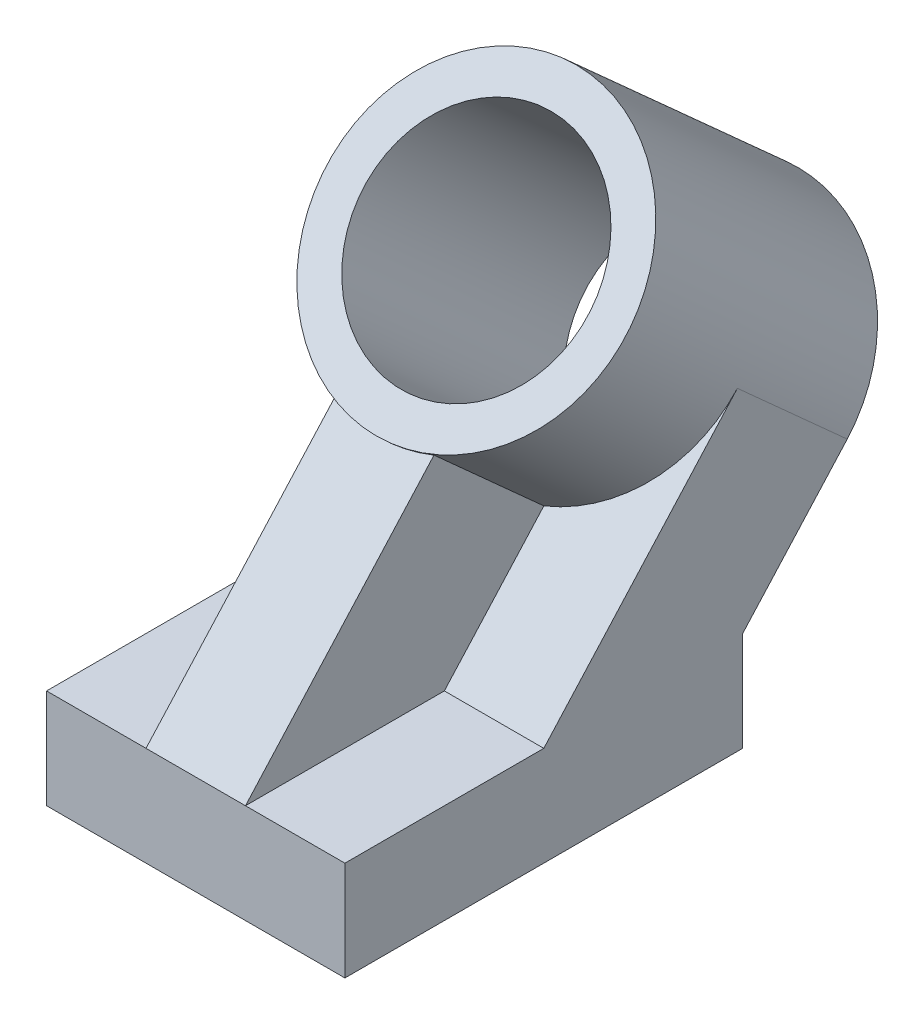
from build123d import *

# Parameters (mm, degrees)
BOSS_EXTRUDE1_DEPTH = 38.1
BOSS_EXTRUDE2_REACH = 114.341
SKETCH3_W           = 25.4
SKETCH3_H           = 88.161149917
SKETCH4_R           = 38.1
BOSS_EXTRUDE3_DEPTH = 76.2
SKETCH5_R           = 28.575
CUT_EXTRUDE1_DEPTH  = 76.2


with BuildPart() as part:
    # Sketch1 → Boss-Extrude1 (new body, symmetric)
    with BuildSketch(Plane(origin=(0, 0, 0), x_dir=(0, 0, -1), z_dir=(1, 0, 0))):
        Polygon((0, 0), (0, 25.4), (50.8, 25.4), (100.244555556, 80.313742191), (128.299578523, 55.052886048), (101.6, 25.4), (101.6, 0), align=None)
    extrude(amount=BOSS_EXTRUDE1_DEPTH, both=True)

    # Sketch3 → Boss-Extrude2 (add, up to next)
    with BuildSketch(Plane(origin=(0, 11.372488517, 12.630428071), x_dir=(1, 0, 0), z_dir=(0, 0.669130606, 0.743144825)), mode=Mode.PRIVATE) as boss_extrude2_sk1:
        with Locations((0, 62.956453526)):
            Rectangle(SKETCH3_W, SKETCH3_H)
    boss_extrude2_tool1 = extrude(boss_extrude2_sk1.sketch, amount=-BOSS_EXTRUDE2_REACH, mode=Mode.PRIVATE) - part.part
    add(boss_extrude2_tool1.solids().sort_by_distance((0, 58.158251, -29.495662))[0])

    # Sketch4 → Boss-Extrude3 (add)
    with BuildSketch(Plane(origin=(0, -39.149223768, -43.479617863), x_dir=(-1, 0, 0), z_dir=(0, -0.669130606, -0.743144825))):
        with Locations((0, 126.761442167)):
            Circle(SKETCH4_R)
    extrude(amount=-BOSS_EXTRUDE3_DEPTH)

    # Sketch5 → Cut-Extrude1 (cut)
    with BuildSketch(Plane(origin=(0, -39.149223768, -43.479617863), x_dir=(-1, 0, 0), z_dir=(0, -0.669130606, -0.743144825))):
        with Locations((0, 126.761442167)):
            Circle(SKETCH5_R)
    extrude(amount=-CUT_EXTRUDE1_DEPTH, mode=Mode.SUBTRACT)


solid = part.part
